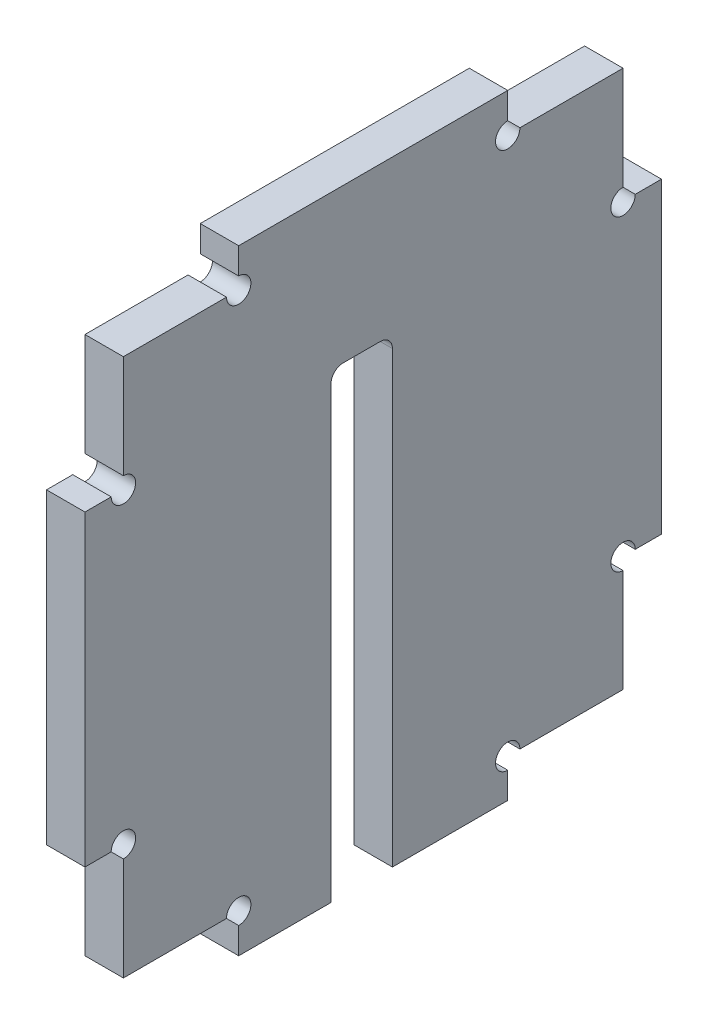
from build123d import *

# Parameters (mm, degrees)
SKETCH1_W                                = 75
SKETCH1_H                                = 80
BOSS_EXTRUDE1_DEPTH                      = 5
CUT_EXTRUDE1_START                       = -6
CUT_EXTRUDE1_DEPTH                       = 7
MIRROR1_START                            = -6
MIRROR1_AT_THE_SECOND_PLANE_COPY_1_DEPTH = 7
CUT_EXTRUDE2_DEPTH                       = 1
CUT_EXTRUDE2_DEPTH_BACK                  = 6
SKETCH5_R                                = 1.5875
CUT_EXTRUDE3_DEPTH                       = 6


with BuildPart() as part:
    # Sketch1 → Boss-Extrude1 (new body)
    with BuildSketch(Plane(origin=(0, 0, 0), x_dir=(0, 0, -1), z_dir=(1, 0, 0))):
        Rectangle(SKETCH1_W, SKETCH1_H)
    extrude(amount=BOSS_EXTRUDE1_DEPTH)

    # Sketch3 → Cut-Extrude1 (cut)
    with BuildSketch(Plane(origin=(5, 0, 0), x_dir=(0, 0, -1), z_dir=(1, 0, 0)).offset(CUT_EXTRUDE1_START)):
        Polygon((-37.5, 20), (-32.5, 20), (-32.5, 35), (-17.5, 35), (-17.5, 40), (-37.5, 40), align=None)
    cut_extrude1 = extrude(amount=CUT_EXTRUDE1_DEPTH, mode=Mode.SUBTRACT)

    # Mirror1: Cut-Extrude1 across plane
    add(cut_extrude1.mirror(Plane.XY), mode=Mode.SUBTRACT)

    # Mirror1 at the second plane: Cut-Extrude1 across plane
    add(cut_extrude1.mirror(Plane.ZX), mode=Mode.SUBTRACT)

    # Mirror1 at the second plane copy 1 sketc → Mirror1 at the second plane copy 1 (cut)
    with BuildSketch(Plane(origin=(5, 0, 0), x_dir=(0, 0, 1), z_dir=(1, 0, 0)).offset(MIRROR1_START)):
        Polygon((-37.5, 20), (-32.5, 20), (-32.5, 35), (-17.5, 35), (-17.5, 40), (-37.5, 40), align=None)
    extrude(amount=MIRROR1_AT_THE_SECOND_PLANE_COPY_1_DEPTH, mode=Mode.SUBTRACT)

    # Sketch4 → Cut-Extrude2 (cut, two sides)
    with BuildSketch(Plane(origin=(5, 0, 0), x_dir=(0, 0, -1), z_dir=(1, 0, 0))) as cut_extrude2_sk:
        with BuildLine():
            Line((-5.5, -40), (-5.5, 18.4125))
            ThreePointArc((-5.5, 18.4125), (-5.035032015, 19.535032015), (-3.9125, 20))
            Line((-3.9125, 20), (0.9125, 20))
            ThreePointArc((0.9125, 20), (2.035032015, 19.535032015), (2.5, 18.4125))
            Line((2.5, 18.4125), (2.5, -40))
            Line((2.5, -40), (-5.5, -40))
        make_face()
    extrude(amount=CUT_EXTRUDE2_DEPTH, mode=Mode.SUBTRACT)
    extrude(cut_extrude2_sk.sketch, amount=-CUT_EXTRUDE2_DEPTH_BACK, mode=Mode.SUBTRACT)

    # Sketch5 → Cut-Extrude3 (cut, through all)
    with BuildSketch(Plane(origin=(5, 0, 0), x_dir=(0, 0, -1), z_dir=(1, 0, 0))):
        with Locations((-17.5, 35)):
            Circle(SKETCH5_R)
        with Locations((-32.5, 20)):
            Circle(SKETCH5_R)
        with Locations((17.5, 35)):
            Circle(SKETCH5_R)
        with Locations((32.5, 20)):
            Circle(SKETCH5_R)
        with Locations((32.5, -20)):
            Circle(SKETCH5_R)
        with Locations((17.5, -35)):
            Circle(SKETCH5_R)
        with Locations((-17.5, -35)):
            Circle(SKETCH5_R)
        with Locations((-32.5, -20)):
            Circle(SKETCH5_R)
    extrude(amount=-CUT_EXTRUDE3_DEPTH, mode=Mode.SUBTRACT)


solid = part.part
